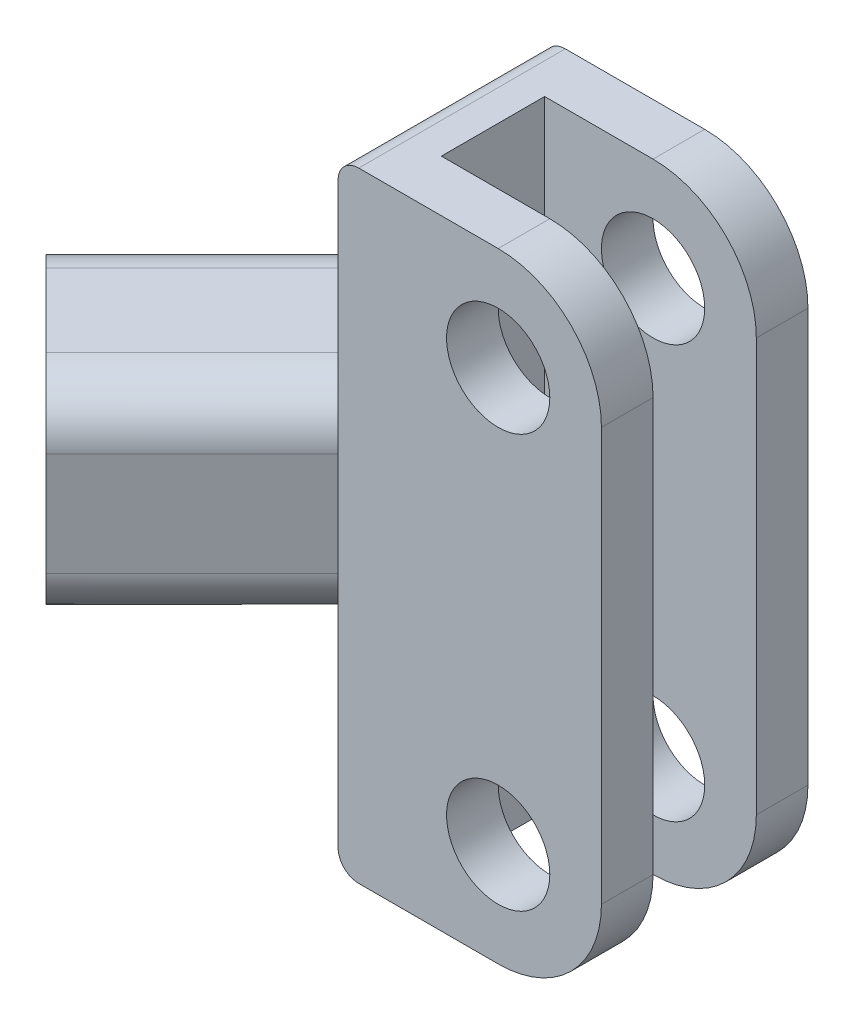
from build123d import *

# Parameters (mm, degrees)
SKETCH1_W           = 5
SKETCH1_H           = 60
BOSS_EXTRUDE1_DEPTH = 5
BOSS_EXTRUDE2_START = 5
SKETCH1_3_R         = 5
SKETCH1_3_W         = 5
SKETCH1_3_H         = 60
BOSS_EXTRUDE2_DEPTH = 5
BOSS_EXTRUDE3_START = -5
SKETCH1_4_R         = 5
SKETCH1_4_W         = 5
SKETCH1_4_H         = 60
BOSS_EXTRUDE3_DEPTH = 5
BOSS_EXTRUDE4_DEPTH = 10
FILLET3_R           = 5
FILLET2_R           = 2
SKETCH4_R           = 7.5
CUT_EXTRUDE1_DEPTH  = 15


with BuildPart() as part:
    # Sketch1 → Boss-Extrude1 (new body, symmetric)
    with BuildSketch(Plane.XY):
        with Locations((-13, 0)):
            Rectangle(SKETCH1_W, SKETCH1_H)
    extrude(amount=BOSS_EXTRUDE1_DEPTH, both=True)

    # Sketch1_3 → Boss-Extrude2 (add)
    with BuildSketch(Plane.XY.offset(BOSS_EXTRUDE2_START)):
        with BuildLine():
            Line((0, 30), (-10.5, 30))
            Line((-10.5, 30), (-10.5, -30))
            Line((-10.5, -30), (0, -30))
            ThreePointArc((0, -30), (7.071067812, -27.071067812), (10, -20))
            Line((10, -20), (10, 20))
            ThreePointArc((10, 20), (7.071067812, 27.071067812), (0, 30))
        make_face()
        with Locations((0, -20)):
            Circle(SKETCH1_3_R, mode=Mode.SUBTRACT)
        with Locations((0, 20)):
            Circle(SKETCH1_3_R, mode=Mode.SUBTRACT)
        with Locations((-13, 0)):
            Rectangle(SKETCH1_3_W, SKETCH1_3_H)
    extrude(amount=BOSS_EXTRUDE2_DEPTH)

    # Sketch1_4 → Boss-Extrude3 (add)
    with BuildSketch(Plane.XY.offset(BOSS_EXTRUDE3_START)):
        with BuildLine():
            Line((0, 30), (-10.5, 30))
            Line((-10.5, 30), (-10.5, -30))
            Line((-10.5, -30), (0, -30))
            ThreePointArc((0, -30), (7.071067812, -27.071067812), (10, -20))
            Line((10, -20), (10, 20))
            ThreePointArc((10, 20), (7.071067812, 27.071067812), (0, 30))
        make_face()
        with Locations((0, -20)):
            Circle(SKETCH1_4_R, mode=Mode.SUBTRACT)
        with Locations((0, 20)):
            Circle(SKETCH1_4_R, mode=Mode.SUBTRACT)
        with Locations((-13, 0)):
            Rectangle(SKETCH1_4_W, SKETCH1_4_H)
    extrude(amount=-BOSS_EXTRUDE3_DEPTH)

    # Sketch3 → Boss-Extrude4 (add, symmetric)
    with BuildSketch(Plane(origin=(0, 0, 0), x_dir=(1, 0, 0), z_dir=(0, 1, 0))):
        with BuildLine():
            Line((-15.5, -10), (-15.5, 10))
            ThreePointArc((-15.5, 10), (-23.153668647, 8.47759065), (-29.642135624, 4.142135624))
            Line((-29.642135624, 4.142135624), (-43.784271247, -10))
            Line((-43.784271247, -10), (-29.642135624, -24.142135624))
            Line((-29.642135624, -24.142135624), (-15.5, -10))
        make_face()
    extrude(amount=BOSS_EXTRUDE4_DEPTH, both=True)

    # Fillet3
    fillet3_edges = [part.edges().sort_by_distance(p)[0] for p in [
        (-22.571067812, -10, 17.071067812),
        (-23.153668647, -10, -8.47759065),
        (-36.713203436, -10, 2.928932188),
        (-22.571067812, 10, 17.071067812),
        (-23.153668647, 10, -8.47759065),
        (-36.713203436, 10, 2.928932188),
    ]]
    fillet(fillet3_edges, radius=FILLET3_R)

    # Fillet2
    fillet2_edges = [part.edges().sort_by_distance(p)[0] for p in [
        (-15.5, 30, 0),
        (-15.5, -30, 0),
    ]]
    fillet(fillet2_edges, radius=FILLET2_R)

    # Sketch4 → Cut-Extrude1 (cut)
    with BuildSketch(Plane(origin=(-26.892135624, 0, 26.892135624), x_dir=(0.707106781, 0, 0.707106781), z_dir=(-0.707106781, 0, 0.707106781))):
        with Locations((-13.889087297, 0)):
            Circle(SKETCH4_R)
    extrude(amount=-CUT_EXTRUDE1_DEPTH, mode=Mode.SUBTRACT)


solid = part.part
